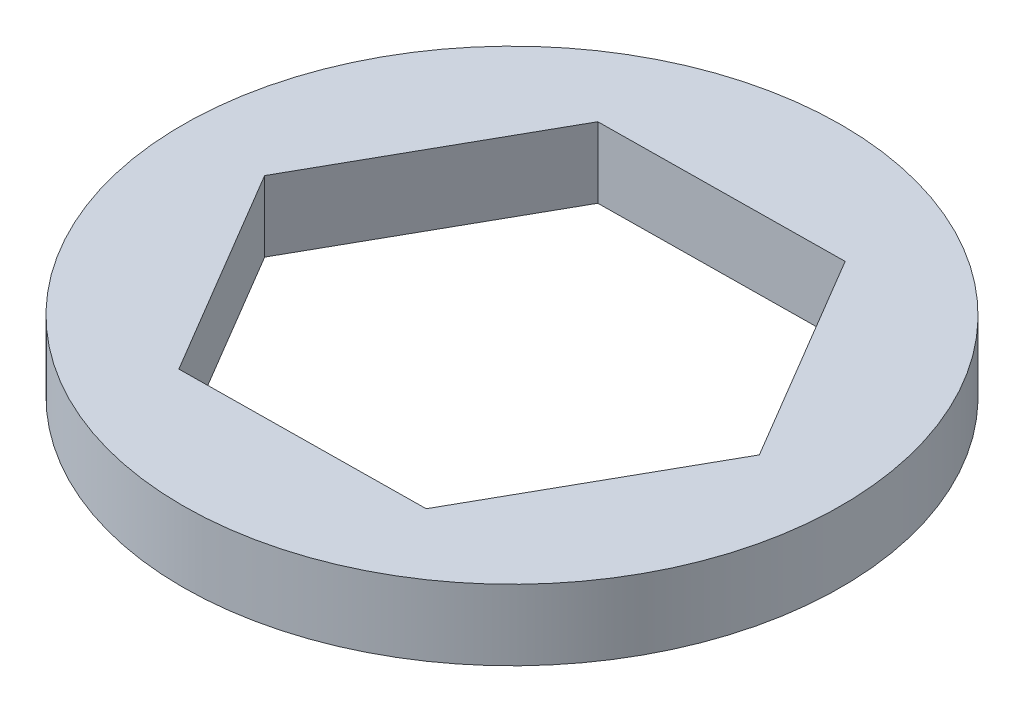
from build123d import *

# Parameters (mm, degrees)
SKETCH1_R           = 8.89
BOSS_EXTRUDE1_DEPTH = 1.905


with BuildPart() as part:
    # Sketch1 → Boss-Extrude1 (new body)
    with BuildSketch(Plane(origin=(0, 0, 0), x_dir=(1, 0, 0), z_dir=(0, 1, 0))):
        Circle(SKETCH1_R)
        Polygon((-3.235289603, -5.75162596), (3.363409393, -5.677655965), (6.598698996, 0.073969996), (3.235289603, 5.75162596), (-3.363409393, 5.677655965), (-6.598698996, -0.073969996), align=None, mode=Mode.SUBTRACT)
    extrude(amount=BOSS_EXTRUDE1_DEPTH)


solid = part.part
